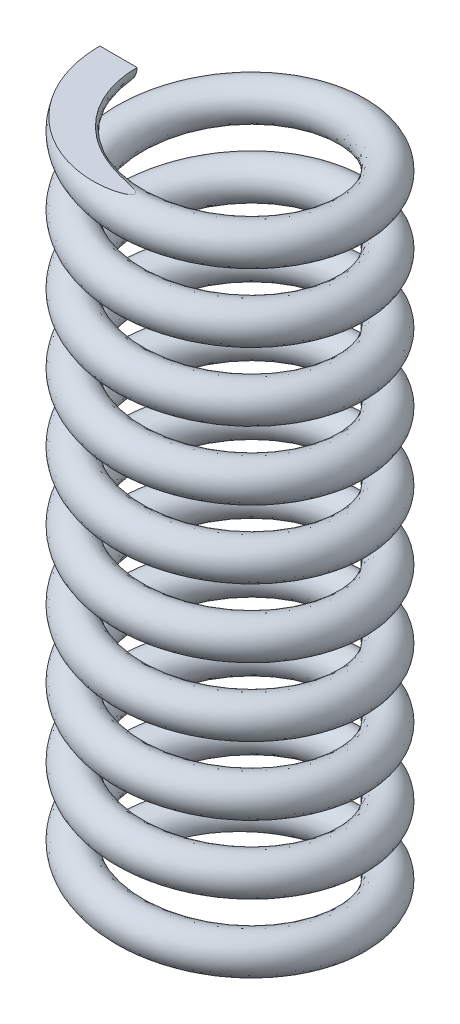
from build123d import *

# Parameters (mm, degrees)
SWEEP1_PITCH       = 18.3642
SWEEP1_HEIGHT      = 183.642
SWEEP1_RADIUS      = 30
SWEEP1_START_ANGLE = -90
SKETCH4_R          = 5
SKETCH5_W          = 171.371046524
SKETCH5_H          = 33.31874617
CUT_EXTRUDE1_DEPTH = 50.8
SKETCH6_W          = 186.317946907
SKETCH6_H          = 34.745351931
CUT_EXTRUDE2_DEPTH = 63.5


with BuildPart() as part:
    # Sweep1: sweep along a helix
    with BuildLine() as sweep1_path:
        add(Helix(SWEEP1_PITCH, SWEEP1_HEIGHT, SWEEP1_RADIUS, center=(0, 0, 0), direction=(0, 1, 0), lefthand=True, mode=Mode.PRIVATE).rotate(Axis((0, 0, 0), (0, 1, 0)), SWEEP1_START_ANGLE))
    # Sketch4 → Sweep1 (sweep)
    with BuildSketch(Plane.XY):
        with Locations((-30, 0)):
            Circle(SKETCH4_R)
    sweep(path=sweep1_path.line, is_frenet=True)

    # Sketch5 → Cut-Extrude1 (cut)
    with BuildSketch(Plane.XY):
        with Locations((6.810712239, -16.659373085)):
            Rectangle(SKETCH5_W, SKETCH5_H)
    extrude(amount=-CUT_EXTRUDE1_DEPTH, mode=Mode.SUBTRACT)

    # Sketch6 → Cut-Extrude2 (cut)
    with BuildSketch(Plane(origin=(0, 0, 0), x_dir=(-1, 0, 0), z_dir=(0, 0, -1))):
        with Locations((1.123418505, 201.014675966)):
            Rectangle(SKETCH6_W, SKETCH6_H)
    extrude(amount=-CUT_EXTRUDE2_DEPTH, mode=Mode.SUBTRACT)


solid = part.part
